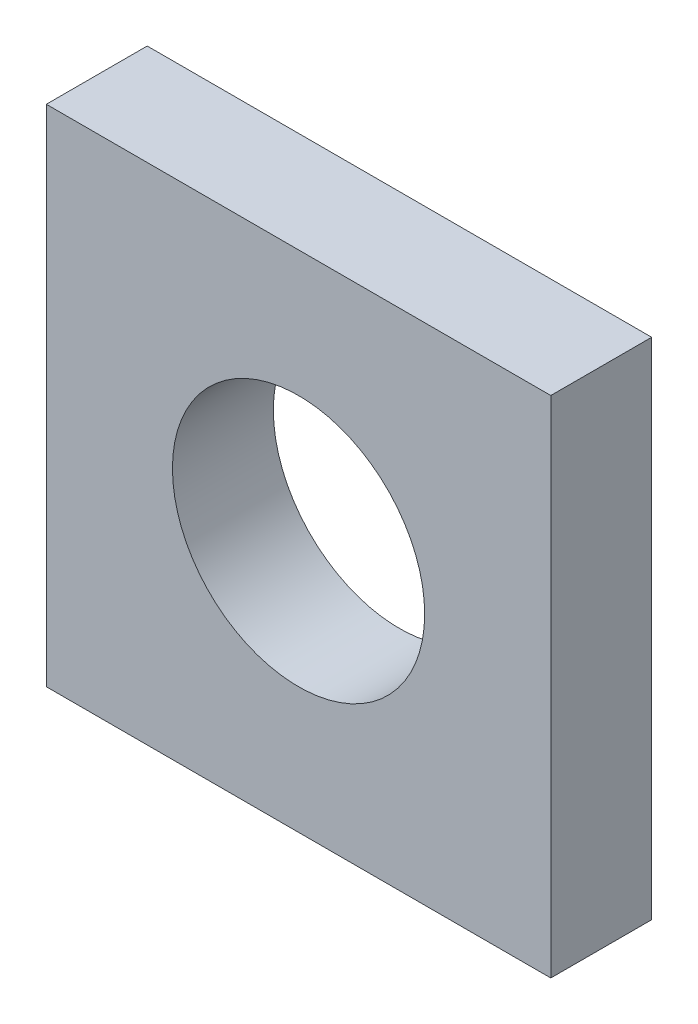
from build123d import *

# Parameters (mm, degrees)
ESQUISSE4_W        = 50
ESQUISSE4_H        = 50
ESQUISSE4_R        = 12.5
BOSS_EXTRU_4_DEPTH = 5


with BuildPart() as part:
    # Esquisse4 → Boss.-Extru.4 (new body, symmetric)
    with BuildSketch(Plane.XY):
        with Locations((-52.568384955, -44.48755358)):
            Rectangle(ESQUISSE4_W, ESQUISSE4_H)
        with Locations((-52.568384955, -44.48755358)):
            Circle(ESQUISSE4_R, mode=Mode.SUBTRACT)
    extrude(amount=BOSS_EXTRU_4_DEPTH, both=True)


solid = part.part
